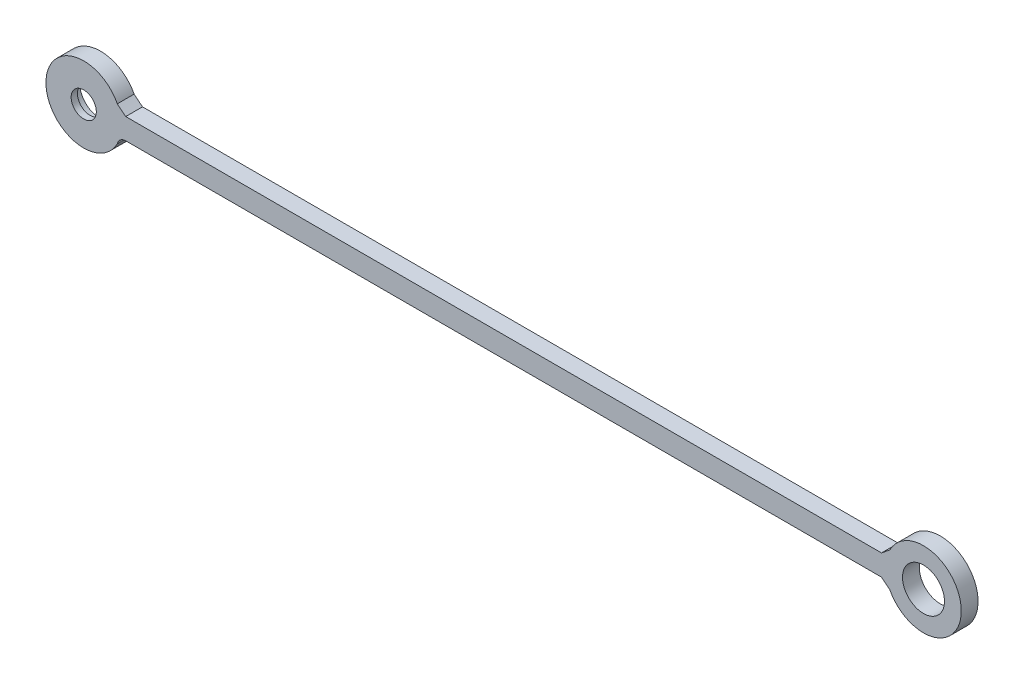
from build123d import *

# Parameters (mm, degrees)
SKETCH_1_R          = 3
SKETCH_1_R_2        = 5
EXTRUDE_1_DEPTH     = 4
SKETCH_1_3_R        = 5
CUT_EXTRUDE_1_DEPTH = 2.5


with BuildPart() as part:
    # 草图1 → 凸台-拉伸1 (new body)
    with BuildSketch(Plane.XY):
        with BuildLine():
            Line((-95, -1.668248682), (85, -1.668248682))
            Line((85, -1.668248682), (87, -3.291354308))
            ThreePointArc((87, -3.291354308), (104, 0.831751318), (87, 4.954856943))
            ThreePointArc((87, 4.954856943), (86.004567475, 4.137676062), (85, 3.331751318))
            Line((85, 3.331751318), (-95, 3.331751318))
            ThreePointArc((-95, 3.331751318), (-96.007924928, 4.133538989), (-97, 4.954856943))
            ThreePointArc((-97, 4.954856943), (-114, 0.831751318), (-97, -3.291354308))
            ThreePointArc((-97, -3.291354308), (-96.287873429, -2.125082216), (-95, -1.668248682))
        make_face()
        with Locations((-105, 0.831751318)):
            Circle(SKETCH_1_R, mode=Mode.SUBTRACT)
        with Locations((95, 0.831751318)):
            Circle(SKETCH_1_R_2, mode=Mode.SUBTRACT)
    extrude(amount=EXTRUDE_1_DEPTH)

    # 草图1<3> → 切除-拉伸1 (cut)
    with BuildSketch(Plane.XY):
        with Locations((-105, 0.831751318)):
            Circle(SKETCH_1_3_R)
    extrude(amount=CUT_EXTRUDE_1_DEPTH, mode=Mode.SUBTRACT)


solid = part.part
